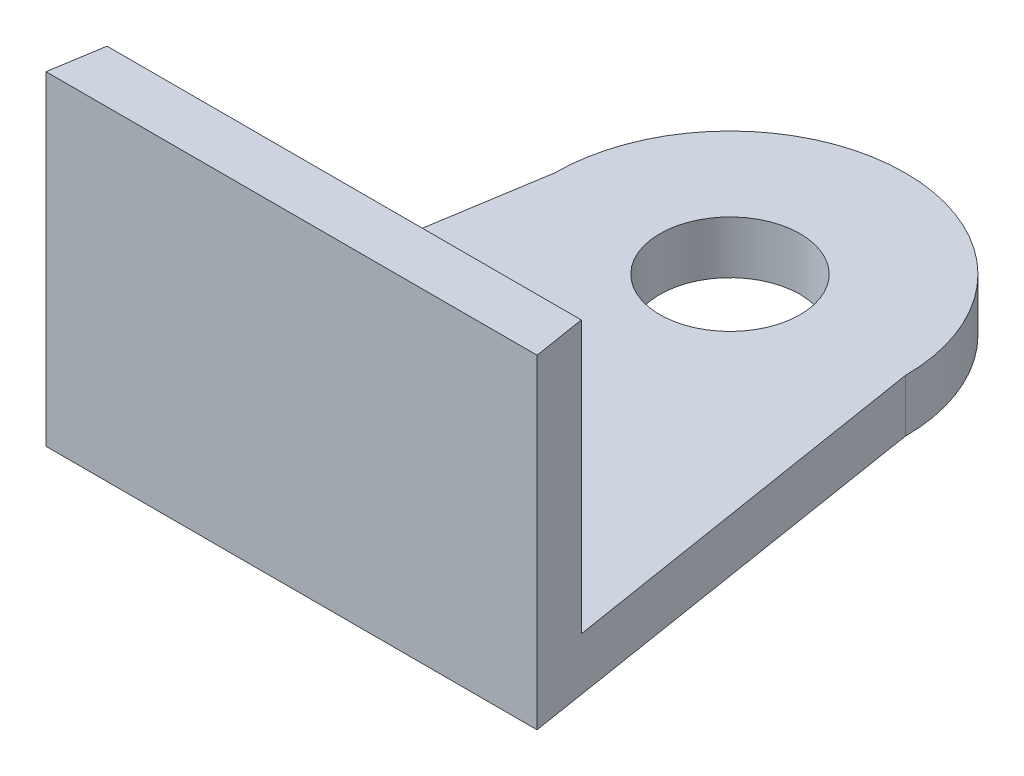
from build123d import *

# Parameters (mm, degrees)
BOSS_EXTRUDE1_DEPTH = 3
SKETCH2_R           = 4
CUT_EXTRUDE1_DEPTH  = 13
BOSS_EXTRUDE2_DEPTH = 15.5
SKETCH6_R           = 4.6
CUT_EXTRUDE4_DEPTH  = 1.5
SKETCH7_R           = 4.6
SKETCH7_R_2         = 4
BOSS_EXTRUDE3_DEPTH = 1.5


with BuildPart() as part:
    # Sketch1 → Boss-Extrude1 (new body)
    with BuildSketch(Plane(origin=(0, 0, 0), x_dir=(1, 0, 0), z_dir=(0, 1, 0))):
        with BuildLine():
            Line((-10, 0), (-14, -25))
            Line((-14, -25), (14, -25))
            Line((14, -25), (10, 0))
            ThreePointArc((10, 0), (0, 10), (-10, 0))
        make_face()
    extrude(amount=BOSS_EXTRUDE1_DEPTH)

    # Sketch2 → Cut-Extrude1 (cut)
    with BuildSketch(Plane(origin=(0, 3, 0), x_dir=(1, 0, 0), z_dir=(0, 1, 0))):
        Circle(SKETCH2_R)
    extrude(amount=-CUT_EXTRUDE1_DEPTH, mode=Mode.SUBTRACT)

    # Sketch5 → Boss-Extrude2 (add)
    with BuildSketch(Plane(origin=(0, 3, 0), x_dir=(1, 0, 0), z_dir=(0, 1, 0))):
        Polygon((-13.52, -22), (13.52, -22), (14, -25), (-14, -25), align=None)
    extrude(amount=BOSS_EXTRUDE2_DEPTH)

    # Sketch6 → Cut-Extrude4 (cut)
    with BuildSketch(Plane(origin=(0, 3, 0), x_dir=(1, 0, 0), z_dir=(0, 1, 0))):
        Circle(SKETCH6_R)
    extrude(amount=-CUT_EXTRUDE4_DEPTH, mode=Mode.SUBTRACT)

    # Sketch7 → Boss-Extrude3 (add)
    with BuildSketch(Plane(origin=(0, 1.5, 0), x_dir=(1, 0, 0), z_dir=(0, 1, 0))):
        Circle(SKETCH7_R)
        Circle(SKETCH7_R_2, mode=Mode.SUBTRACT)
    extrude(amount=BOSS_EXTRUDE3_DEPTH)


solid = part.part
